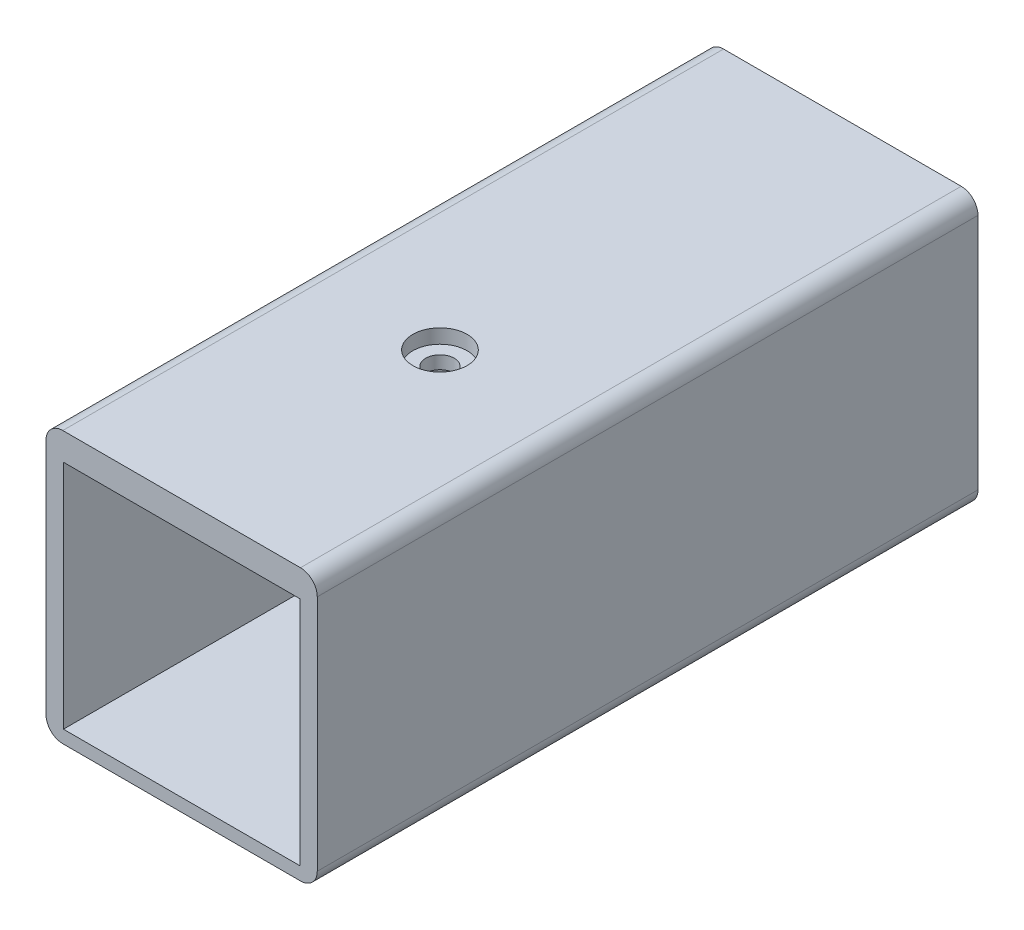
from build123d import *

# Parameters (mm, degrees)
EXTRUDE_1_DEPTH     = 51.15
SKETCH_3_W          = 18.3
SKETCH_3_H          = 17.9
CUT_EXTRUDE_1_DEPTH = 50.35
SKETCH_6_W          = 18.3
SKETCH_6_H          = 2.5
EXTRUDE_5_DEPTH     = 2.5
SKETCH_4_W          = 15.2
SKETCH_4_H          = 12.4
CUT_EXTRUDE_4_DEPTH = 5.5
SKETCH_12_R         = 1.1
CUT_EXTRUDE_5_DEPTH = 7.5
SKETCH_13_R         = 2.1
CUT_EXTRUDE_6_DEPTH = 1.1
SKETCH_14_W         = 2.068898905
SKETCH_14_H         = 0.355441082
CUT_EXTRUDE_7_DEPTH = 0.4


with BuildPart() as part:
    # 草图1 → 凸台-拉伸1 (new body)
    with BuildSketch(Plane.XY):
        with BuildLine():
            Line((-9.2, -10.5), (9.2, -10.5))
            ThreePointArc((9.2, -10.5), (10.119238816, -10.119238816), (10.5, -9.2))
            Line((10.5, -9.2), (10.5, 9.2))
            ThreePointArc((10.5, 9.2), (10.119238816, 10.119238816), (9.2, 10.5))
            Line((9.2, 10.5), (-9.2, 10.5))
            ThreePointArc((-9.2, 10.5), (-10.119238816, 10.119238816), (-10.5, 9.2))
            Line((-10.5, 9.2), (-10.5, -9.2))
            ThreePointArc((-10.5, -9.2), (-10.119238816, -10.119238816), (-9.2, -10.5))
        make_face()
    extrude(amount=EXTRUDE_1_DEPTH)

    # 草图3 → 切除-拉伸1 (cut)
    with BuildSketch(Plane.XY.offset(51.15)):
        with Locations((0, -0.55)):
            Rectangle(SKETCH_3_W, SKETCH_3_H)
    extrude(amount=-CUT_EXTRUDE_1_DEPTH, mode=Mode.SUBTRACT)

    # 草图6 → 凸台-拉伸5 (add)
    with BuildSketch(Plane.XY.offset(0.8)):
        with Locations((0, -8.25)):
            Rectangle(SKETCH_6_W, SKETCH_6_H)
    extrude(amount=EXTRUDE_5_DEPTH)

    # 草图4 → 切除-拉伸4 (cut)
    with BuildSketch(Plane(origin=(0, 0, 0), x_dir=(-1, 0, 0), z_dir=(0, 0, -1))):
        with Locations((0, 0.9)):
            Rectangle(SKETCH_4_W, SKETCH_4_H)
    extrude(amount=-CUT_EXTRUDE_4_DEPTH, mode=Mode.SUBTRACT)

    # 草图12 → 切除-拉伸5 (cut)
    with BuildSketch(Plane(origin=(0, 10.5, 0), x_dir=(1, 0, 0), z_dir=(0, 1, 0))):
        with Locations((0, -31.15)):
            Circle(SKETCH_12_R)
    extrude(amount=-CUT_EXTRUDE_5_DEPTH, mode=Mode.SUBTRACT)

    # 草图13 → 切除-拉伸6 (cut)
    with BuildSketch(Plane(origin=(0, 10.5, 0), x_dir=(1, 0, 0), z_dir=(0, 1, 0))):
        with Locations((0, -31.15)):
            Circle(SKETCH_13_R)
    extrude(amount=-CUT_EXTRUDE_6_DEPTH, mode=Mode.SUBTRACT)

    # 草图14 → 切除-拉伸7 (cut)
    with BuildSketch(Plane.ZY.offset(10.5)):
        with BuildLine():
            add(Edge.make_bspline(
                [(16.849410119, -0.291946599), (16.848575705, -0.325452312), (16.846940328, -0.391120475), (16.836834718, -0.487476033), (16.818694908, -0.57897977), (16.793926341, -0.665873271), (16.760483866, -0.747233401), (16.721390303, -0.824615099), (16.674093759, -0.896760772), (16.620015993, -0.96407697), (16.558154816, -1.025458249), (16.486353964, -1.07754425), (16.406580966, -1.122531097), (16.317631197, -1.158127376), (16.220449277, -1.186743368), (16.114457958, -1.205991364), (15.999965384, -1.218673724), (15.920707233, -1.219858604), (15.879674125, -1.220472034)],
                knots=[0, 0, 0, 0, 0.000100525, 0.00019702, 0.000290216, 0.000380081, 0.000467609, 0.000553715, 0.0006398, 0.000725883, 0.000812398, 0.00090036, 0.000991173, 0.001086474, 0.001187131, 0.001294603, 0.001409231, 0.001532279, 0.001532279, 0.001532279, 0.001532279], degree=3))
            add(Edge.make_bspline(
                [(15.879674125, -1.220472034), (15.841011191, -1.219761241), (15.766076466, -1.218383614), (15.657667154, -1.206934578), (15.5572167, -1.187063996), (15.464793449, -1.159255952), (15.379660644, -1.124952927), (15.302859052, -1.081359381), (15.234345707, -1.029712767), (15.173887867, -0.970334554), (15.121202541, -0.904661343), (15.075876538, -0.832962735), (15.036973808, -0.756087765), (15.005734696, -0.673539107), (14.980946157, -0.585877155), (14.964088227, -0.492712308), (14.952520763, -0.394190237), (14.951612903, -0.326538645), (14.95114869, -0.291946599)],
                knots=[0, 0, 0, 0, 0.000115969, 0.000224766, 0.000326549, 0.000422702, 0.00051394, 0.000601316, 0.000686829, 0.000770612, 0.000854883, 0.00093884, 0.001024655, 0.001112908, 0.001203215, 0.001297555, 0.00139668, 0.0015004, 0.0015004, 0.0015004, 0.0015004], degree=3))
            Line((14.95114869, -0.291946599), (14.95114869, 1.813655461))
            Line((14.95114869, 1.813655461), (15.466924607, 1.813655461))
            Line((15.466924607, 1.813655461), (15.466924607, -0.291946599))
            add(Edge.make_bspline(
                [(15.466924607, -0.291946599), (15.467356532, -0.31491756), (15.468189232, -0.359202929), (15.472798942, -0.422993576), (15.482848832, -0.481432927), (15.495389787, -0.534678307), (15.511344663, -0.58326872), (15.53192459, -0.62616519), (15.555796919, -0.664314261), (15.592705984, -0.706758816), (15.645801142, -0.749709606), (15.717442102, -0.786990479), (15.796195795, -0.810768127), (15.851384558, -0.813011647), (15.879674125, -0.814161667)],
                knots=[0, 0, 0, 0, 6.8926e-05, 0.000132881, 0.000191633, 0.000246608, 0.000296903, 0.000344714, 0.000389013, 0.000431477, 0.000512937, 0.000592141, 0.00067263, 0.00075728, 0.00075728, 0.00075728, 0.00075728], degree=3))
            add(Edge.make_bspline(
                [(15.879674125, -0.814161667), (15.91222892, -0.812810032), (15.974811409, -0.810211684), (16.063983717, -0.786568624), (16.14244292, -0.746530809), (16.1996843, -0.701154134), (16.237990058, -0.656462516), (16.264278649, -0.618412314), (16.284991572, -0.574621145), (16.303294628, -0.527206748), (16.316660535, -0.474876158), (16.326178073, -0.418017051), (16.3319483, -0.356456588), (16.332636459, -0.313852301), (16.332990287, -0.291946599)],
                knots=[0, 0, 0, 0, 9.7538e-05, 0.000187504, 0.000274184, 0.000360267, 0.000404547, 0.000450446, 0.000498538, 0.000549484, 0.000602743, 0.000660225, 0.000722311, 0.000788019, 0.000788019, 0.000788019, 0.000788019], degree=3))
            Line((16.332990287, -0.291946599), (16.332990287, 1.813655461))
            Line((16.332990287, 1.813655461), (16.849410119, 1.813655461))
            Line((16.849410119, 1.813655461), (16.849410119, -0.291946599))
        make_face()
        with BuildLine():
            add(Edge.make_bspline(
                [(19.132732721, -0.326074095), (19.13215977, -0.358536656), (19.131039375, -0.422016653), (19.117280353, -0.514834898), (19.097217274, -0.603196225), (19.068100696, -0.687116594), (19.029875026, -0.765739378), (18.983611928, -0.839917164), (18.929525559, -0.909684509), (18.866972406, -0.973837207), (18.797444433, -1.032272619), (18.720244884, -1.08212435), (18.637622063, -1.125923641), (18.548010876, -1.160464077), (18.452292338, -1.18754495), (18.350135876, -1.206607846), (18.241617594, -1.218409101), (18.167106082, -1.219772423), (18.128869231, -1.220472034)],
                knots=[0, 0, 0, 0, 9.7308e-05, 0.000190284, 0.000280875, 0.000368849, 0.000456111, 0.00054259, 0.000630691, 0.000720398, 0.000810923, 0.000902542, 0.000995572, 0.001090993, 0.001190056, 0.001293612, 0.001402409, 0.001517091, 0.001517091, 0.001517091, 0.001517091], degree=3))
            add(Edge.make_bspline(
                [(18.128869231, -1.220472034), (18.092781872, -1.219753363), (18.022557441, -1.21835486), (17.920130465, -1.206831864), (17.823981406, -1.186551293), (17.733258555, -1.16011425), (17.649045633, -1.124204362), (17.570700952, -1.081158601), (17.498673262, -1.029782245), (17.433263049, -0.971272911), (17.374617593, -0.90691855), (17.323830315, -0.837868145), (17.280071904, -0.765193618), (17.244625036, -0.688555481), (17.21759101, -0.607687479), (17.197418653, -0.523295214), (17.185774037, -0.43457783), (17.184334458, -0.37418659), (17.183602006, -0.3434598)],
                knots=[0, 0, 0, 0, 0.000108247, 0.000210643, 0.000308641, 0.000402759, 0.000493651, 0.000582712, 0.00067044, 0.000758459, 0.000845521, 0.000931164, 0.001015202, 0.001099616, 0.001183917, 0.0012706, 0.001359574, 0.001451735, 0.001451735, 0.001451735, 0.001451735], degree=3))
            Line((17.183602006, -0.3434598), (17.183602006, -0.182481049))
            Line((17.183602006, -0.182481049), (17.699377924, -0.182481049))
            Line((17.699377924, -0.182481049), (17.699377924, -0.326074095))
            add(Edge.make_bspline(
                [(17.699377924, -0.326074095), (17.699654367, -0.34627295), (17.70019114, -0.385493387), (17.707031446, -0.442280534), (17.716668605, -0.495070098), (17.732029628, -0.543418329), (17.750326908, -0.587856299), (17.773132868, -0.628358686), (17.800118918, -0.664813635), (17.842021506, -0.70570303), (17.898610207, -0.748530835), (17.971646545, -0.786449872), (18.04915055, -0.809597564), (18.102100139, -0.812629066), (18.128869231, -0.814161667)],
                knots=[0, 0, 0, 0, 6.0559e-05, 0.000117588, 0.000171385, 0.000221283, 0.000269478, 0.000315323, 0.000360397, 0.000405018, 0.00049053, 0.000572317, 0.000650772, 0.00073099, 0.00073099, 0.00073099, 0.00073099], degree=3))
            add(Edge.make_bspline(
                [(18.128869231, -0.814161667), (18.149278371, -0.813870102), (18.18891838, -0.813303806), (18.246193884, -0.806688952), (18.299366575, -0.79638529), (18.348421449, -0.782770603), (18.392666298, -0.763563623), (18.433074383, -0.741327809), (18.468695547, -0.713801869), (18.510615686, -0.672703496), (18.553114912, -0.613831479), (18.590827908, -0.53568288), (18.613252749, -0.450081269), (18.615704144, -0.390597639), (18.616956803, -0.36020159)],
                knots=[0, 0, 0, 0, 6.1202e-05, 0.000118871, 0.000172668, 0.000223615, 0.000271217, 0.000317061, 0.000361622, 0.00040579, 0.000492852, 0.000577815, 0.000664962, 0.00075603, 0.00075603, 0.00075603, 0.00075603], degree=3))
            add(Edge.make_bspline(
                [(18.616956803, -0.36020159), (18.615186016, -0.334851174), (18.611589499, -0.283363784), (18.582440102, -0.208370894), (18.535941853, -0.136535258), (18.471326829, -0.067160175), (18.388094809, -0.000198497), (18.285977829, 0.065245292), (18.164673833, 0.129522541), (18.075525934, 0.167632207), (18.02841849, 0.187770078)],
                knots=[0, 0, 0, 0, 7.5875e-05, 0.000154105, 0.000238061, 0.000331491, 0.000437189, 0.000557746, 0.000694862, 0.000848504, 0.000848504, 0.000848504, 0.000848504], degree=3))
            add(Edge.make_bspline(
                [(18.02841849, 0.187770078), (17.995924938, 0.200442378), (17.932891979, 0.225024873), (17.842252352, 0.264302944), (17.758356223, 0.305406471), (17.681417174, 0.348544157), (17.610559084, 0.392267023), (17.546846818, 0.437845574), (17.489897977, 0.485050143), (17.439186965, 0.533382438), (17.394984277, 0.584019079), (17.356737878, 0.637005523), (17.324548644, 0.692509747), (17.297813514, 0.750213966), (17.277213007, 0.810431236), (17.262186077, 0.873129986), (17.254022164, 0.938360369), (17.252584042, 0.982555353), (17.251856996, 1.004898217)],
                knots=[0, 0, 0, 0, 0.000104626, 0.000202959, 0.000296263, 0.000384761, 0.000467486, 0.000545932, 0.000619556, 0.000689233, 0.000755865, 0.000820913, 0.000884968, 0.000948066, 0.001011396, 0.001075587, 0.001141159, 0.001208204, 0.001208204, 0.001208204, 0.001208204], degree=3))
            add(Edge.make_bspline(
                [(17.251856996, 1.004898217), (17.252507897, 1.035634704), (17.253778796, 1.095648369), (17.266403262, 1.183475452), (17.286978009, 1.266722531), (17.315274496, 1.345578667), (17.351636949, 1.4201017), (17.397052471, 1.489569048), (17.450127, 1.554964954), (17.510541711, 1.615147539), (17.57650896, 1.669381906), (17.646082962, 1.717432682), (17.719359896, 1.757478498), (17.79550062, 1.790287664), (17.874475778, 1.81648901), (17.956745695, 1.834199277), (18.041842214, 1.845495767), (18.099642519, 1.847014838), (18.128869231, 1.847782956)],
                knots=[0, 0, 0, 0, 9.2161e-05, 0.000179946, 0.000265529, 0.000349039, 0.000430824, 0.000513697, 0.000597468, 0.000683067, 0.000769058, 0.000853359, 0.000936354, 0.001019129, 0.001101802, 0.001185543, 0.001271242, 0.001358899, 0.001358899, 0.001358899, 0.001358899], degree=3))
            add(Edge.make_bspline(
                [(18.128869231, 1.847782956), (18.168835651, 1.846999535), (18.24600837, 1.845486796), (18.357175204, 1.831634156), (18.459736244, 1.810125802), (18.553529208, 1.779569551), (18.638279824, 1.739183583), (18.714335946, 1.690385659), (18.780660464, 1.631504309), (18.837871987, 1.564865839), (18.886526178, 1.492668619), (18.930143805, 1.418730816), (18.966358558, 1.342154151), (18.99585266, 1.263701392), (19.019312376, 1.183229377), (19.036151724, 1.100567808), (19.045847971, 1.015649725), (19.047104666, 0.958345678), (19.04773594, 0.929560162)],
                knots=[0, 0, 0, 0, 0.000119853, 0.000231429, 0.000335496, 0.000433847, 0.000526588, 0.000616426, 0.000704017, 0.00079167, 0.000879188, 0.000964889, 0.001048993, 0.00113295, 0.001216092, 0.001300196, 0.00138574, 0.001472085, 0.001472085, 0.001472085, 0.001472085], degree=3))
            Line((19.04773594, 0.929560162), (18.531316108, 0.929560162))
            add(Edge.make_bspline(
                [(18.531316108, 0.929560162), (18.532713572, 0.963943555), (18.535393297, 1.029875847), (18.520310432, 1.12512713), (18.489675185, 1.211204489), (18.44927988, 1.273463419), (18.411833038, 1.31762224), (18.380017845, 1.346268632), (18.344863836, 1.369932662), (18.30762169, 1.390354001), (18.266888776, 1.405018951), (18.223535079, 1.415855656), (18.177206387, 1.423386172), (18.145212519, 1.423849966), (18.128869231, 1.424086884)],
                knots=[0, 0, 0, 0, 0.000103028, 0.000197563, 0.0002874, 0.00037511, 0.000418482, 0.000460888, 0.000503039, 0.000545386, 0.000587967, 0.000632476, 0.000679376, 0.000728352, 0.000728352, 0.000728352, 0.000728352], degree=3))
            add(Edge.make_bspline(
                [(18.128869231, 1.424086884), (18.103216584, 1.423083876), (18.053842845, 1.421153382), (17.983476739, 1.403246078), (17.920543653, 1.374059992), (17.865559669, 1.333175857), (17.820728518, 1.280207544), (17.78961985, 1.214811515), (17.770921185, 1.138788297), (17.768768174, 1.084430029), (17.767632914, 1.055767502)],
                knots=[0, 0, 0, 0, 7.6845e-05, 0.000147903, 0.000216173, 0.000283785, 0.000351884, 0.000422151, 0.000499144, 0.000585026, 0.000585026, 0.000585026, 0.000585026], degree=3))
            add(Edge.make_bspline(
                [(17.767632914, 1.055767502), (17.76851075, 1.031636498), (17.77021721, 0.984727288), (17.786616119, 0.917688195), (17.813704221, 0.857298805), (17.844336806, 0.810938667), (17.878617856, 0.777187945), (17.912738139, 0.75046235), (17.956009341, 0.72296238), (18.007159184, 0.693343628), (18.067573134, 0.663562208), (18.135521216, 0.631071364), (18.212707522, 0.598497158), (18.267063799, 0.57661137), (18.295643217, 0.56510427)],
                knots=[0, 0, 0, 0, 7.2302e-05, 0.000140551, 0.000205408, 0.000270242, 0.000305757, 0.000349301, 0.000400023, 0.000459445, 0.000526542, 0.000602009, 0.000685376, 0.000777806, 0.000777806, 0.000777806, 0.000777806], degree=3))
            add(Edge.make_bspline(
                [(18.295643217, 0.56510427), (18.328827105, 0.551231832), (18.393636328, 0.524138505), (18.486572131, 0.479445102), (18.573316288, 0.433187381), (18.654485959, 0.385635657), (18.728933887, 0.335229905), (18.797941646, 0.283960102), (18.861063754, 0.230960686), (18.917469129, 0.175684557), (18.968210109, 0.118951748), (19.011946244, 0.060217764), (19.049841588, 0.00023458), (19.08014847, -0.061767157), (19.103560862, -0.125460207), (19.120236376, -0.190825332), (19.131066426, -0.257887562), (19.132175724, -0.303281223), (19.132732721, -0.326074095)],
                knots=[0, 0, 0, 0, 0.000107886, 0.000210705, 0.000309224, 0.00040276, 0.00049277, 0.000578797, 0.000660585, 0.000739815, 0.000815535, 0.000888684, 0.000959259, 0.001028086, 0.001095312, 0.001162468, 0.001230223, 0.001298554, 0.001298554, 0.001298554, 0.001298554], degree=3))
        make_face()
        with BuildLine():
            add(Edge.make_bspline(
                [(21.433441027, -0.275204809), (21.43269787, -0.315602379), (21.431261901, -0.393660764), (21.416862873, -0.505986504), (21.393906053, -0.609160045), (21.362076086, -0.703287258), (21.320005059, -0.787766029), (21.268606906, -0.862725853), (21.208158723, -0.928764938), (21.138010098, -0.984559309), (21.060841675, -1.031872481), (20.978624022, -1.073079855), (20.891653246, -1.108909055), (20.798957963, -1.136698031), (20.701455772, -1.159823838), (20.598409302, -1.174422437), (20.490312977, -1.184699572), (20.416510898, -1.185787357), (20.378708252, -1.186344539)],
                knots=[0, 0, 0, 0, 0.00012114, 0.000234073, 0.000339047, 0.00043781, 0.000531399, 0.000621239, 0.000709645, 0.000798945, 0.000889179, 0.000980753, 0.001074619, 0.001170959, 0.001270768, 0.001374947, 0.001482913, 0.001596288, 0.001596288, 0.001596288, 0.001596288], degree=3))
            Line((20.378708252, -1.186344539), (19.484310313, -1.186344539))
            Line((19.484310313, -1.186344539), (19.484310313, 1.813655461))
            Line((19.484310313, 1.813655461), (20.412835747, 1.813655461))
            add(Edge.make_bspline(
                [(20.412835747, 1.813655461), (20.451060631, 1.812871923), (20.525099545, 1.811354265), (20.632496598, 1.800889087), (20.731973462, 1.780961506), (20.824745102, 1.75613356), (20.909365495, 1.721549932), (20.986819151, 1.680459589), (21.056431481, 1.631021689), (21.117828245, 1.574370033), (21.171528825, 1.513061115), (21.219047522, 1.449763947), (21.259190035, 1.384099195), (21.291445888, 1.315712806), (21.317536457, 1.245632941), (21.335677262, 1.172868607), (21.345917999, 1.09791537), (21.3475973, 1.047211992), (21.348444247, 1.021640007)],
                knots=[0, 0, 0, 0, 0.000114682, 0.000222131, 0.000323158, 0.000418772, 0.000509767, 0.000596772, 0.000681282, 0.000765139, 0.000846795, 0.000925482, 0.001002343, 0.001077228, 0.001151992, 0.00122633, 0.001301731, 0.001378454, 0.001378454, 0.001378454, 0.001378454], degree=3))
            add(Edge.make_bspline(
                [(21.348444247, 1.021640007), (21.347923357, 0.996509949), (21.346910586, 0.947649367), (21.339840236, 0.876593312), (21.328044426, 0.810320231), (21.310106754, 0.749101781), (21.288949468, 0.692343647), (21.261259959, 0.641063016), (21.229799913, 0.594022399), (21.181810072, 0.540485118), (21.119877587, 0.484794446), (21.046451481, 0.431575701), (20.975603827, 0.394361626), (20.927416204, 0.383479347), (20.90478681, 0.378368919)],
                knots=[0, 0, 0, 0, 7.5382e-05, 0.000146566, 0.000214008, 0.000276984, 0.00033773, 0.000395342, 0.000451422, 0.00050709, 0.000610568, 0.000700617, 0.000778945, 0.000848296, 0.000848296, 0.000848296, 0.000848296], degree=3))
            add(Edge.make_bspline(
                [(20.90478681, 0.378368919), (20.934759052, 0.37221209), (20.996722467, 0.359483707), (21.086545042, 0.316710532), (21.175179131, 0.255725003), (21.245736725, 0.1916099), (21.300453668, 0.133459873), (21.335433915, 0.084050064), (21.366505083, 0.032324606), (21.390467832, -0.023322935), (21.410283119, -0.081563956), (21.423464795, -0.143378094), (21.432197416, -0.208200776), (21.433022181, -0.252637971), (21.433441027, -0.275204809)],
                knots=[0, 0, 0, 0, 9.1518e-05, 0.0001892, 0.000295822, 0.000413466, 0.00047454, 0.000534948, 0.000594693, 0.000655235, 0.000716322, 0.000778971, 0.000844543, 0.000912203, 0.000912203, 0.000912203, 0.000912203], degree=3))
        make_face()
        with BuildLine():
            add(Edge.make_bspline(
                [(20.832024414, 1.021640007), (20.831624352, 1.037965683), (20.8308537, 1.069414268), (20.82578677, 1.11492167), (20.816876419, 1.157044316), (20.803980452, 1.195635577), (20.787907134, 1.231065733), (20.767651838, 1.262627572), (20.74461783, 1.291513277), (20.707818742, 1.323823725), (20.656763749, 1.357988947), (20.587138176, 1.386587761), (20.510736907, 1.404293908), (20.457151152, 1.406308464), (20.429577537, 1.407345094)],
                knots=[0, 0, 0, 0, 4.8976e-05, 9.4343e-05, 0.000137157, 0.000177882, 0.000216199, 0.000253535, 0.000290142, 0.000326613, 0.000400014, 0.000473321, 0.000551267, 0.000633891, 0.000633891, 0.000633891, 0.000633891], degree=3))
            Line((20.429577537, 1.407345094), (20.00008623, 1.407345094))
            Line((20.00008623, 1.407345094), (20.00008623, 0.585065635))
            Line((20.00008623, 0.585065635), (20.412835747, 0.585065635))
            add(Edge.make_bspline(
                [(20.412835747, 0.585065635), (20.440635694, 0.586281416), (20.494960921, 0.588657232), (20.573187402, 0.607882355), (20.645343046, 0.639004856), (20.699366922, 0.675767427), (20.738314935, 0.711333926), (20.763565342, 0.743362872), (20.784753416, 0.779645723), (20.802148247, 0.819882051), (20.815821112, 0.864342186), (20.825114758, 0.913143562), (20.831020189, 0.966118886), (20.831682477, 1.002735143), (20.832024414, 1.021640007)],
                knots=[0, 0, 0, 0, 8.3314e-05, 0.000162808, 0.000240089, 0.000317957, 0.000357594, 0.000397919, 0.000439774, 0.000483318, 0.000529144, 0.000579026, 0.000632144, 0.000688842, 0.000688842, 0.000688842, 0.000688842], degree=3))
        make_face(mode=Mode.SUBTRACT)
        with BuildLine():
            add(Edge.make_bspline(
                [(20.900279405, -0.275204809), (20.899807855, -0.25521886), (20.898891414, -0.216376798), (20.891201571, -0.160442044), (20.878350528, -0.109006482), (20.860527172, -0.062286846), (20.836798017, -0.020426901), (20.808617598, 0.017221937), (20.774545552, 0.049867782), (20.722452813, 0.086218714), (20.651446523, 0.123783894), (20.559633727, 0.155054984), (20.46244601, 0.175382767), (20.395554948, 0.177613606), (20.361322547, 0.178755268)],
                knots=[0, 0, 0, 0, 5.9939e-05, 0.00011649, 0.000168965, 0.000218709, 0.000265992, 0.000312869, 0.000359321, 0.000406853, 0.000503061, 0.00059918, 0.000697048, 0.000799633, 0.000799633, 0.000799633, 0.000799633], degree=3))
            Line((20.361322547, 0.178755268), (20.00008623, 0.178755268))
            Line((20.00008623, 0.178755268), (20.00008623, -0.780034172))
            Line((20.00008623, -0.780034172), (20.310453262, -0.780034172))
            add(Edge.make_bspline(
                [(20.310453262, -0.780034172), (20.334288351, -0.779646688), (20.380299199, -0.778898696), (20.447150822, -0.773633655), (20.509310239, -0.7654586), (20.567106246, -0.754109182), (20.620028182, -0.7385591), (20.668558204, -0.719955056), (20.712782564, -0.69811913), (20.752597514, -0.672253071), (20.787840263, -0.641625532), (20.818694242, -0.605896216), (20.843624832, -0.563736176), (20.86507484, -0.516814957), (20.880896025, -0.463900463), (20.892514643, -0.405933986), (20.898587079, -0.342298767), (20.899699841, -0.298182183), (20.900279405, -0.275204809)],
                knots=[0, 0, 0, 0, 7.1501e-05, 0.000138024, 0.000201042, 0.000259511, 0.000314527, 0.000366305, 0.000415259, 0.00046223, 0.000508327, 0.000554912, 0.000603171, 0.000654757, 0.000709342, 0.000768442, 0.000831873, 0.00090082, 0.00090082, 0.00090082, 0.00090082], degree=3))
        make_face(mode=Mode.SUBTRACT)
        with Locations((24.949538903, 0.356475809)):
            Rectangle(SKETCH_14_W, SKETCH_14_H)
        Polygon((30.465636777, -1.186344539), (28.601502843, -1.186344539), (28.601502843, 1.813655461), (30.380639997, 1.813655461), (30.380639997, 1.407345094), (29.117922676, 1.407345094), (29.117922676, 0.585065635), (30.278257512, 0.585065635), (30.278257512, 0.178755268), (29.117922676, 0.178755268), (29.117922676, -0.780034172), (30.465636777, -0.780034172), align=None)
        Polygon((32.698090094, 1.407345094), (32.01554019, 1.407345094), (32.01554019, -1.186344539), (31.499764273, -1.186344539), (31.499764273, 1.407345094), (30.817214369, 1.407345094), (30.817214369, 1.813655461), (32.698090094, 1.813655461), align=None)
        Polygon((34.964670905, -1.186344539), (34.448894987, -1.186344539), (34.448894987, 0.178755268), (33.599571098, 0.178755268), (33.599571098, -1.186344539), (33.083795181, -1.186344539), (33.083795181, 1.813655461), (33.599571098, 1.813655461), (33.599571098, 0.585065635), (34.448894987, 0.585065635), (34.448894987, 1.813655461), (34.964670905, 1.813655461), align=None)
    extrude(amount=-CUT_EXTRUDE_7_DEPTH, mode=Mode.SUBTRACT)


solid = part.part
